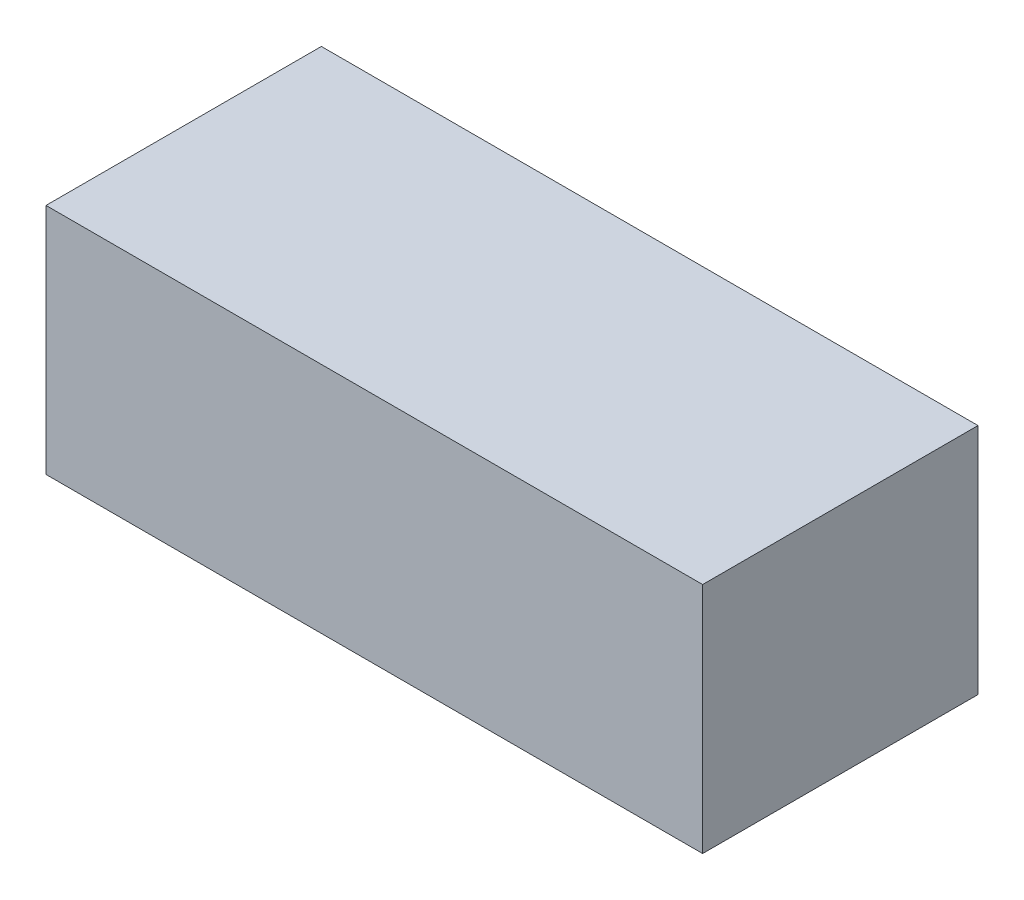
from build123d import *

# Parameters (mm, degrees)
SKETCH1_W           = 31
SKETCH1_H           = 13
BOSS_EXTRUDE1_DEPTH = 11


with BuildPart() as part:
    # Sketch1 → Boss-Extrude1 (new body)
    with BuildSketch(Plane(origin=(0, 0, 0), x_dir=(1, 0, 0), z_dir=(0, 1, 0))):
        with Locations((-0.131355932, 6.963983051)):
            Rectangle(SKETCH1_W, SKETCH1_H)
    extrude(amount=BOSS_EXTRUDE1_DEPTH)


solid = part.part
